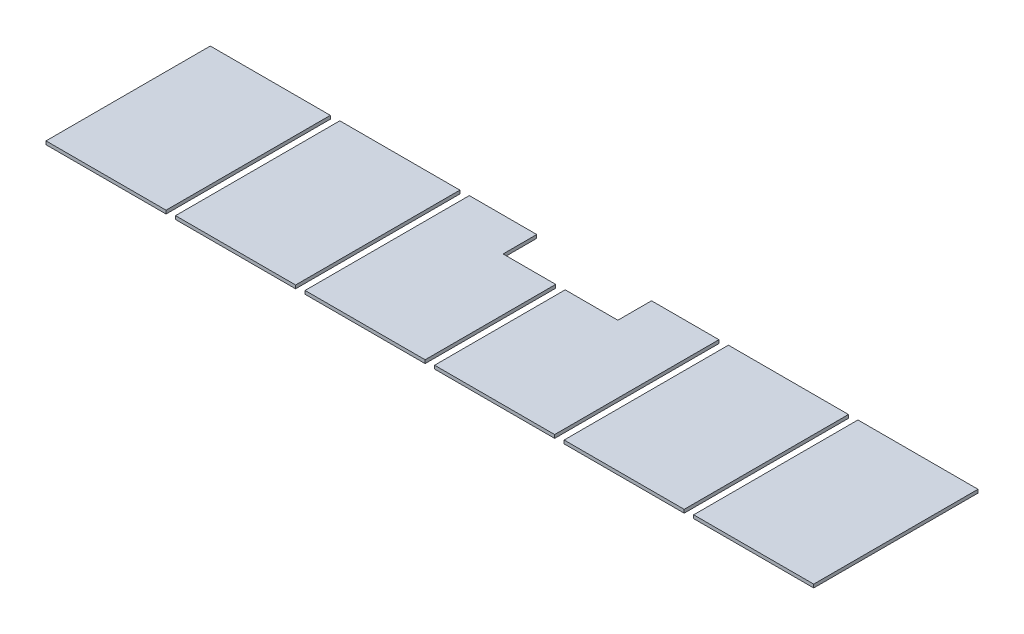
from build123d import *

# Parameters (mm, degrees)
SKETCH2_W             = 1447.8
SKETCH2_H             = 1981.2
BOSS_EXTRUDE1_DEPTH   = 40.64
BOSS_EXTRUDE1_2_DEPTH = 40.64
BOSS_EXTRUDE1_3_DEPTH = 40.64
BOSS_EXTRUDE1_4_DEPTH = 40.64
BOSS_EXTRUDE1_5_DEPTH = 40.64
BOSS_EXTRUDE1_6_DEPTH = 40.64


with BuildPart() as part:
    # Sketch2 → Boss-Extrude1 (new body)
    with BuildSketch(Plane(origin=(0, 0, 0), x_dir=(1, 0, 0), z_dir=(0, 1, 0))):
        with Locations((787.4, 1054.1)):
            Rectangle(SKETCH2_W, SKETCH2_H)
    extrude(amount=BOSS_EXTRUDE1_DEPTH)


with BuildPart() as body_2:
    # Sketch2 → Boss-Extrude1 2 (new body)
    with BuildSketch(Plane(origin=(0, 0, 0), x_dir=(1, 0, 0), z_dir=(0, 1, 0))):
        with Locations((2349.5, 1054.1)):
            Rectangle(SKETCH2_W, SKETCH2_H)
    extrude(amount=BOSS_EXTRUDE1_2_DEPTH)


with BuildPart() as body_3:
    # Sketch2 → Boss-Extrude1 3 (new body)
    with BuildSketch(Plane(origin=(0, 0, 0), x_dir=(1, 0, 0), z_dir=(0, 1, 0))):
        Polygon((3187.7, 2044.7), (3187.7, 63.5), (4635.5, 63.5), (4635.5, 1638.3), (4000.5, 1638.3), (4000.5, 2044.7), align=None)
    extrude(amount=BOSS_EXTRUDE1_3_DEPTH)


with BuildPart() as body_4:
    # Sketch2 → Boss-Extrude1 4 (new body)
    with BuildSketch(Plane(origin=(0, 0, 0), x_dir=(1, 0, 0), z_dir=(0, 1, 0))):
        Polygon((6197.6, 2044.7), (5384.8, 2044.7), (5384.8, 1638.3), (4749.8, 1638.3), (4749.8, 63.5), (6197.6, 63.5), align=None)
    extrude(amount=BOSS_EXTRUDE1_4_DEPTH)


with BuildPart() as body_5:
    # Sketch2 → Boss-Extrude1 5 (new body)
    with BuildSketch(Plane(origin=(0, 0, 0), x_dir=(1, 0, 0), z_dir=(0, 1, 0))):
        with Locations((7035.8, 1054.1)):
            Rectangle(SKETCH2_W, SKETCH2_H)
    extrude(amount=BOSS_EXTRUDE1_5_DEPTH)


with BuildPart() as body_6:
    # Sketch2 → Boss-Extrude1 6 (new body)
    with BuildSketch(Plane(origin=(0, 0, 0), x_dir=(1, 0, 0), z_dir=(0, 1, 0))):
        with Locations((8597.9, 1054.1)):
            Rectangle(SKETCH2_W, SKETCH2_H)
    extrude(amount=BOSS_EXTRUDE1_6_DEPTH)


solid = Compound([part.part, body_2.part, body_3.part, body_4.part, body_5.part, body_6.part])
